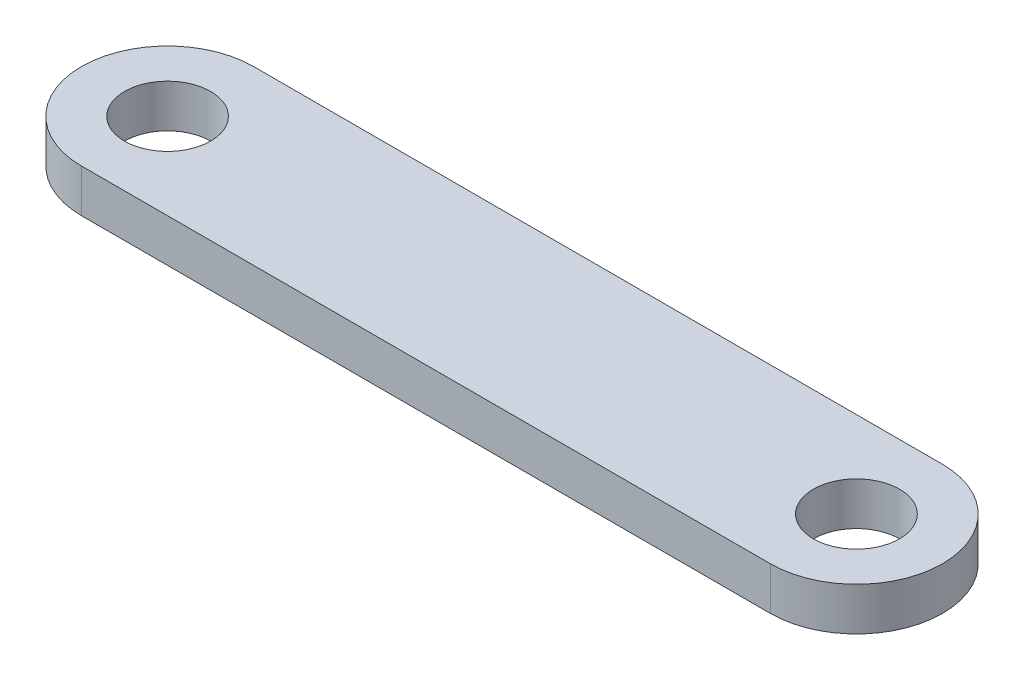
from build123d import *

# Parameters (mm, degrees)
SKETCH2_R           = 2
BOSS_EXTRUDE1_DEPTH = 1


with BuildPart() as part:
    # Sketch2 → Boss-Extrude1 (new body, symmetric)
    with BuildSketch(Plane(origin=(0, 0, 0), x_dir=(1, 0, 0), z_dir=(0, 1, 0))):
        with BuildLine():
            Line((-16, 4), (16, 4))
            ThreePointArc((16, 4), (20, 0), (16, -4))
            Line((16, -4), (-16, -4))
            ThreePointArc((-16, -4), (-20, 0), (-16, 4))
        make_face()
        with Locations((16, 0)):
            Circle(SKETCH2_R, mode=Mode.SUBTRACT)
        with Locations((-16, 0)):
            Circle(SKETCH2_R, mode=Mode.SUBTRACT)
    extrude(amount=BOSS_EXTRUDE1_DEPTH, both=True)


solid = part.part
